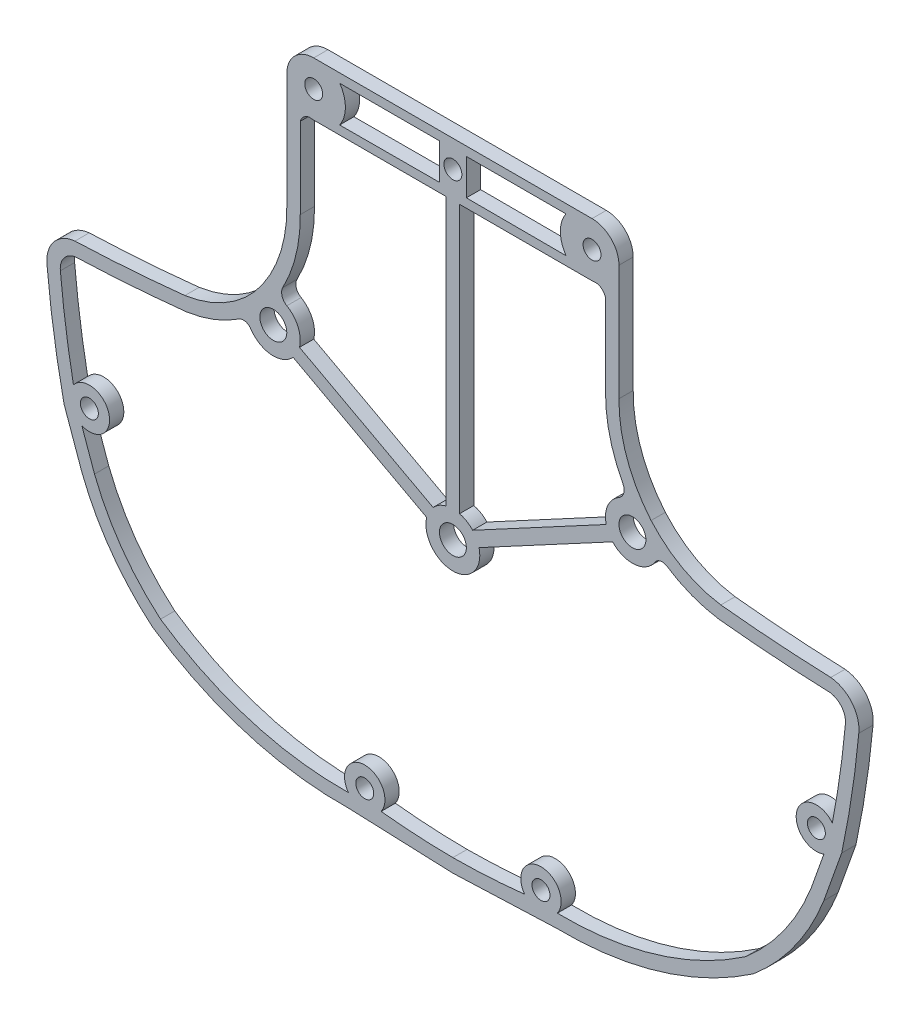
from build123d import *

# Parameters (mm, degrees)
SKETCH4_R           = 1
SKETCH4_R_2         = 1.5
SKETCH4_R_3         = 1.500000001
BOSS_EXTRUDE2_DEPTH = 1.5875


with BuildPart() as part:
    # Sketch4 → Boss-Extrude2 (new body)
    with BuildSketch(Plane.XY):
        with BuildLine():
            ThreePointArc((-33.472754103, -25.121469845), (-23.054804413, -30.112701264), (-11.610361031, -31.68457355))
            Line((-11.610361031, -31.68457355), (0, -32.144613372))
            Line((0, -32.144613372), (11.610361031, -31.68457355))
            ThreePointArc((11.610361031, -31.68457355), (23.054804413, -30.112701264), (33.472754103, -25.121469845))
            ThreePointArc((33.472754103, -25.121469845), (38.084735692, -20.128369992), (41.315395383, -14.148047401))
            Line((41.315395383, -14.148047401), (43.310324676, -8.545068137))
            ThreePointArc((43.310324676, -8.545068137), (44.448650445, -2.324461154), (45.212741618, 3.953110149))
            ThreePointArc((45.212741618, 3.953110149), (44.453814547, 6.519739723), (42.09374947, 7.782138432))
            ThreePointArc((42.09374947, 7.782138432), (35.962680022, 8.111048014), (29.846780413, 8.653234381))
            ThreePointArc((29.846780413, 8.653234381), (25.580679904, 10.088760175), (22.077124707, 12.914613823))
            ThreePointArc((22.077124707, 12.914613823), (19.390258386, 17.570844388), (18.500000009, 22.872464303))
            Line((18.500000009, 22.872464303), (18.500000009, 35.75))
            ThreePointArc((18.500000009, 35.75), (17.62132035, 37.87132035), (15.5, 38.750000009))
            Line((15.5, 38.750000009), (-15.5, 38.750000009))
            ThreePointArc((-15.5, 38.750000009), (-17.62132035, 37.87132035), (-18.500000009, 35.75))
            Line((-18.500000009, 35.75), (-18.500000009, 22.872464277))
            ThreePointArc((-18.500000009, 22.872464277), (-19.390258383, 17.570844381), (-22.07712469, 12.91461383))
            ThreePointArc((-22.07712469, 12.91461383), (-25.580679805, 10.088760216), (-29.846780215, 8.653234395))
            ThreePointArc((-29.846780215, 8.653234395), (-35.962679941, 8.111048017), (-42.093749505, 7.78213843))
            ThreePointArc((-42.093749505, 7.78213843), (-44.453814559, 6.519739711), (-45.212741618, 3.953110149))
            ThreePointArc((-45.212741618, 3.953110149), (-44.448650445, -2.324461154), (-43.310324676, -8.545068137))
            Line((-43.310324676, -8.545068137), (-41.315395383, -14.148047401))
            ThreePointArc((-41.315395383, -14.148047401), (-38.084735692, -20.128369992), (-33.472754103, -25.121469845))
        make_face()
        with Locations((-9.815163292, -28.866300371)):
            Circle(SKETCH4_R, mode=Mode.SUBTRACT)
        with Locations((-40.488991371, -7.557479081)):
            Circle(SKETCH4_R, mode=Mode.SUBTRACT)
        with BuildLine():
            Line((-39.916947455, -13.605513167), (-41.326325711, -9.6458687))
            ThreePointArc((-41.326325711, -9.6458687), (-38.316546684, -6.971830651), (-42.262559751, -6.172937569))
            ThreePointArc((-42.262559751, -6.172937569), (-43.119549374, -1.052504396), (-43.720300768, 4.104274139))
            ThreePointArc((-43.720300768, 4.104274139), (-43.306279922, 5.553180603), (-41.988991391, 6.284955247))
            ThreePointArc((-41.988991391, 6.284955247), (-35.815859297, 6.617706074), (-29.658025423, 7.164848598))
            ThreePointArc((-29.658025423, 7.164848598), (-26.630229039, 7.954390182), (-23.847155024, 9.384574043))
            ThreePointArc((-23.847155024, 9.384574043), (-23.125480938, 9.525676377), (-22.515405804, 9.115150267))
            ThreePointArc((-22.515405804, 9.115150267), (-20.254015304, 7.760773306), (-17.79651867, 8.714153732))
            Line((-17.79651867, 8.714153732), (-2.913646, 0.714609672))
            ThreePointArc((-2.913646, 0.714609672), (0, -3), (2.913646001, 0.714609672))
            Line((2.913646001, 0.714609672), (17.79651867, 8.714153732))
            ThreePointArc((17.79651867, 8.714153732), (20.254015126, 7.760773291), (22.515405609, 9.115149969))
            ThreePointArc((22.515405609, 9.115149969), (23.125480765, 9.52567634), (23.847155026, 9.384574041))
            ThreePointArc((23.847155026, 9.384574041), (26.630229041, 7.954390183), (29.658025423, 7.164848601))
            ThreePointArc((29.658025423, 7.164848601), (35.815859287, 6.617706075), (41.988991371, 6.284955244))
            ThreePointArc((41.988991371, 6.284955244), (43.306279914, 5.553180608), (43.720300768, 4.104274139))
            ThreePointArc((43.720300768, 4.104274139), (43.119549374, -1.052504396), (42.262559751, -6.172937569))
            ThreePointArc((42.262559751, -6.172937569), (38.316546684, -6.971830651), (41.326325712, -9.6458687))
            Line((41.326325712, -9.6458687), (39.916947456, -13.605513167))
            ThreePointArc((39.916947456, -13.605513167), (36.88563151, -19.226390572), (32.562542901, -23.926820768))
            ThreePointArc((32.562542901, -23.926820768), (22.58818115, -28.686629582), (11.638338487, -30.184834485))
            ThreePointArc((11.638338487, -30.184834485), (9.815163292, -26.616300371), (7.991988098, -30.184834485))
            ThreePointArc((7.991988098, -30.184834485), (4.00190894, -30.517536934), (0, -30.644609524))
            ThreePointArc((0, -30.644609524), (-4.00190894, -30.517536934), (-7.991988097, -30.184834485))
            ThreePointArc((-7.991988097, -30.184834485), (-9.815163292, -26.616300371), (-11.638338487, -30.184834485))
            ThreePointArc((-11.638338487, -30.184834485), (-22.58818115, -28.686629582), (-32.562542901, -23.926820768))
            ThreePointArc((-32.562542901, -23.926820768), (-36.88563151, -19.226390572), (-39.916947455, -13.605513167))
        make_face(mode=Mode.SUBTRACT)
        with Locations((9.815163292, -28.866300371)):
            Circle(SKETCH4_R, mode=Mode.SUBTRACT)
        Circle(SKETCH4_R_2, mode=Mode.SUBTRACT)
        with Locations((40.488991371, -7.557479081)):
            Circle(SKETCH4_R, mode=Mode.SUBTRACT)
        with Locations((-20.000000001, 10.750000001)):
            Circle(SKETCH4_R_3, mode=Mode.SUBTRACT)
        with BuildLine():
            ThreePointArc((-18.952977672, 14.865256843), (-17.471741936, 18.750329795), (-17.000000007, 22.881347914))
            Line((-17.000000007, 22.881347914), (-17.000000007, 31.885058019))
            ThreePointArc((-17.000000007, 31.885058019), (-16.616434483, 32.496276684), (-15.954980266, 32.784701868))
            ThreePointArc((-15.954980266, 32.784701868), (-15.728150861, 32.758688041), (-15.5, 32.749999991))
            Line((-15.5, 32.749999991), (-0.750000001, 32.749999991))
            Line((-0.750000001, 32.749999991), (-0.750000001, 2.90473751))
            ThreePointArc((-0.750000001, 2.90473751), (-1.539319977, 2.574974565), (-2.20348133, 2.035846268))
            Line((-2.20348133, 2.035846268), (-17.086354, 10.035390328))
            ThreePointArc((-17.086354, 10.035390328), (-17.239112062, 11.923668519), (-18.492829269, 13.343922973))
            ThreePointArc((-18.492829269, 13.343922973), (-18.498254435, 13.347040523), (-18.503662642, 13.3501874))
            ThreePointArc((-18.503662642, 13.3501874), (-19.027733875, 14.018926796), (-18.952977672, 14.865256843))
        make_face(mode=Mode.SUBTRACT)
        with Locations((-15.5, 35.75)):
            Circle(SKETCH4_R, mode=Mode.SUBTRACT)
        with BuildLine():
            Line((-12.592865853, 37.75), (-1.5, 37.75))
            Line((-1.5, 37.75), (-1.5, 33.75))
            Line((-1.5, 33.75), (-12.612506492, 33.721747011))
            ThreePointArc((-12.612506492, 33.721747011), (-11.971383706, 35.732795451), (-12.592865853, 37.75))
        make_face(mode=Mode.SUBTRACT)
        with Locations((20, 10.75)):
            Circle(SKETCH4_R_2, mode=Mode.SUBTRACT)
        with BuildLine():
            Line((17.000000002, 31.88505801), (17.000000002, 22.881347906))
            ThreePointArc((17.000000002, 22.881347906), (17.471741935, 18.750329789), (18.952977675, 14.865256841))
            ThreePointArc((18.952977675, 14.865256841), (19.027733877, 14.018926793), (18.503662642, 13.350187397))
            ThreePointArc((18.503662642, 13.350187397), (18.498254436, 13.347040521), (18.492829272, 13.343922972))
            ThreePointArc((18.492829271, 13.343922974), (17.239112062, 11.923668519), (17.086354, 10.035390328))
            Line((17.086354, 10.035390328), (2.20348133, 2.035846268))
            ThreePointArc((2.20348133, 2.035846268), (1.539319976, 2.574974565), (0.749999999, 2.90473751))
            Line((0.749999999, 2.90473751), (0.749999999, 32.749999991))
            Line((0.749999999, 32.749999991), (15.5, 32.749999991))
            ThreePointArc((15.5, 32.749999991), (15.728150862, 32.758688041), (15.954980267, 32.784701869))
            ThreePointArc((15.954980267, 32.784701869), (16.616434482, 32.496276679), (17.000000002, 31.88505801))
        make_face(mode=Mode.SUBTRACT)
        with Locations((0, 35.75)):
            Circle(SKETCH4_R, mode=Mode.SUBTRACT)
        with BuildLine():
            Line((1.5, 33.75), (1.5, 37.75))
            Line((1.5, 37.75), (12.592865854, 37.75))
            ThreePointArc((12.592865854, 37.75), (11.971383706, 35.732795451), (12.612506492, 33.721747011))
            Line((12.612506492, 33.721747011), (1.5, 33.75))
        make_face(mode=Mode.SUBTRACT)
        with Locations((15.5, 35.75)):
            Circle(SKETCH4_R, mode=Mode.SUBTRACT)
    extrude(amount=BOSS_EXTRUDE2_DEPTH)


solid = part.part
